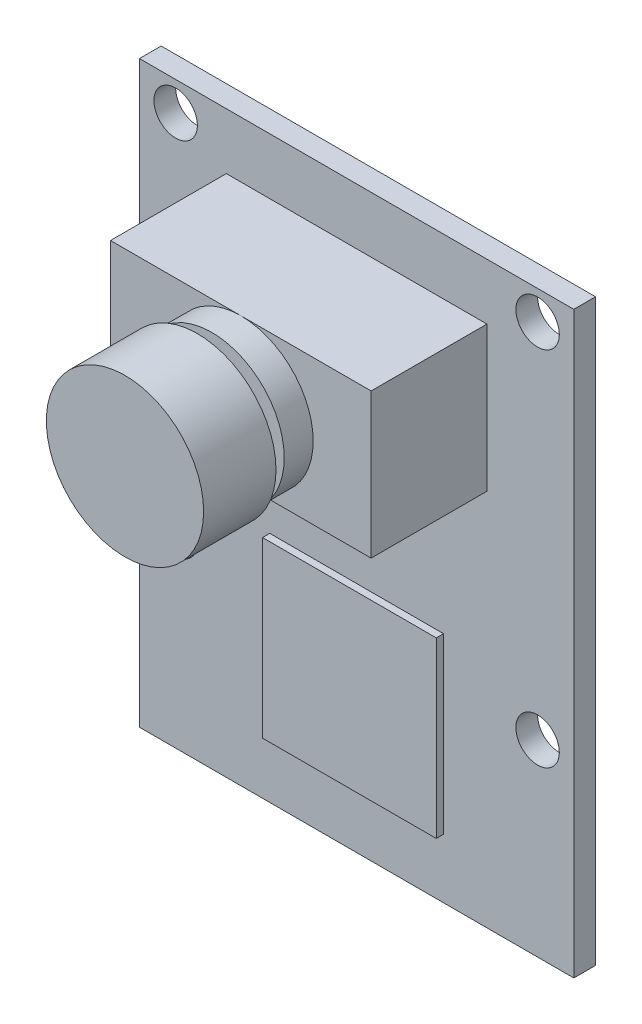
from build123d import *

# Parameters (mm, degrees)
SKETCH_1_W          = 30
SKETCH_1_H          = 40
EXTRUDE_1_DEPTH     = 1.5
SKETCH_2_R          = 1.5
CUT_EXTRUDE_1_DEPTH = 2.5
SKETCH_3_W          = 18
SKETCH_3_H          = 10
EXTRUDE_2_DEPTH     = 8
SKETCH_4_R          = 5
EXTRUDE_3_DEPTH     = 2
SKETCH_5_R          = 3.78256648
EXTRUDE_4_DEPTH     = 1
SKETCH_6_R          = 5.431564172
EXTRUDE_5_DEPTH     = 5
SKETCH_7_W          = 12
SKETCH_7_H          = 12
EXTRUDE_6_DEPTH     = 0.5


with BuildPart() as part:
    # 草图1 → 凸台-拉伸1 (new body)
    with BuildSketch(Plane.XY):
        Rectangle(SKETCH_1_W, SKETCH_1_H)
    extrude(amount=EXTRUDE_1_DEPTH)

    # 草图2 → 切除-拉伸1 (cut, through all)
    with BuildSketch(Plane.XY.offset(1.5)):
        with Locations((-12.5, 17.989454292)):
            Circle(SKETCH_2_R)
        with Locations((12.5, 17.989454292)):
            Circle(SKETCH_2_R)
        with Locations((-12.5, -7.010545708)):
            Circle(SKETCH_2_R)
        with Locations((12.5, -7.010545708)):
            Circle(SKETCH_2_R)
    extrude(amount=-CUT_EXTRUDE_1_DEPTH, mode=Mode.SUBTRACT)

    # 草图3 → 凸台-拉伸2 (add)
    with BuildSketch(Plane.XY.offset(1.5)):
        with Locations((0, 11.11683457)):
            Rectangle(SKETCH_3_W, SKETCH_3_H)
    extrude(amount=EXTRUDE_2_DEPTH)

    # 草图4 → 凸台-拉伸3 (add)
    with BuildSketch(Plane.XY.offset(9.5)):
        with Locations((0, 11.11683457)):
            Circle(SKETCH_4_R)
    extrude(amount=EXTRUDE_3_DEPTH)

    # 草图5 → 凸台-拉伸4 (add)
    with BuildSketch(Plane.XY.offset(11.5)):
        with Locations((0, 11.11683457)):
            Circle(SKETCH_5_R)
    extrude(amount=EXTRUDE_4_DEPTH)

    # 草图6 → 凸台-拉伸5 (add)
    with BuildSketch(Plane.XY.offset(12.5)):
        with Locations((0, 11.11683457)):
            Circle(SKETCH_6_R)
    extrude(amount=EXTRUDE_5_DEPTH)

    # 草图7 → 凸台-拉伸6 (add)
    with BuildSketch(Plane.XY.offset(1.5)):
        with Locations((0, -9.903085883)):
            Rectangle(SKETCH_7_W, SKETCH_7_H)
    extrude(amount=EXTRUDE_6_DEPTH)


solid = part.part
